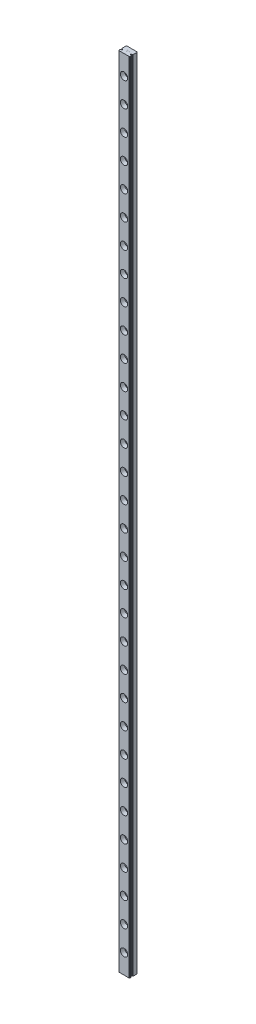
from build123d import *

# Parameters (mm, degrees)
SALIENTE_EXTRUIR1_DEPTH = 652
CORTAR_EXTRUIR1_DEPTH   = 653
CORTAR_EXTRUIR2_DEPTH   = 653
CORTAR_EXTRUIR3_DEPTH   = 653
CORTAR_EXTRUIR4_DEPTH   = 653
CORTAR_EXTRUIR5_DEPTH   = 653
CORTAR_EXTRUIR6_DEPTH   = 653
CORTAR_EXTRUIR7_DEPTH   = 0.002166667
CORTAR_EXTRUIR8_DEPTH   = 0.002166667
CORTAR_EXTRUIR9_DEPTH   = 0.002166667
CORTAR_EXTRUIR10_DEPTH  = 0.002166667
NGULO_DE_SALIDA1_ANGLE  = 45.1469538
CHAFL_N1_SIZE           = 0.4
REDONDEO1_R             = 0.130000023
MATRIZL2_COUNT          = 32
MATRIZL2_PITCH          = 20


with BuildPart() as part:
    # Croquis1 → Saliente-Extruir1 (new body)
    with BuildSketch(Plane.XZ):
        Polygon((4.5, 0), (4.5, 6.01167813), (4.1, 6.50000002), (-4.1, 6.50000002), (-4.5, 6.01167813), (-4.5, 0), align=None)
    extrude(amount=-SALIENTE_EXTRUIR1_DEPTH)

    # Croquis2 → Cortar-Extruir1 (cut, through all)
    with BuildSketch(Plane(origin=(0, 652, 0), x_dir=(-1, 0, 0), z_dir=(0, 1, 0))):
        with BuildLine():
            Line((-4.5, 4.88017535), (-4.5, 4.03150278))
            Line((-4.5, 4.03150278), (-3.819258765, 4.03150278))
            ThreePointArc((-3.819258765, 4.03150278), (-3.21946318, 4.455839065), (-3.819258765, 4.88017535))
            Line((-3.819258765, 4.88017535), (-4.5, 4.88017535))
        make_face()
    extrude(amount=-CORTAR_EXTRUIR1_DEPTH, mode=Mode.SUBTRACT)

    # Croquis3 → Cortar-Extruir2 (cut, through all)
    with BuildSketch(Plane(origin=(0, 652, 0), x_dir=(-1, 0, 0), z_dir=(0, 1, 0))):
        with BuildLine():
            Line((-4.026513856, 4.03150278), (-4.5, 4.03150278))
            Line((-4.5, 4.03150278), (-4.5, 3.583620931))
            ThreePointArc((-4.5, 3.583620931), (-4.223645982, 3.76568645), (-4.026513856, 4.03150278))
        make_face()
    extrude(amount=-CORTAR_EXTRUIR2_DEPTH, mode=Mode.SUBTRACT)

    # Croquis4 → Cortar-Extruir3 (cut, through all)
    with BuildSketch(Plane(origin=(0, 652, 0), x_dir=(-1, 0, 0), z_dir=(0, 1, 0))):
        with BuildLine():
            Line((-4.5, 5.328056964), (-4.5, 4.88017535))
            Line((-4.5, 4.88017535), (-4.026513974, 4.88017535))
            ThreePointArc((-4.026513974, 4.88017535), (-4.223646078, 5.145991535), (-4.5, 5.328056964))
        make_face()
    extrude(amount=-CORTAR_EXTRUIR3_DEPTH, mode=Mode.SUBTRACT)

    # Croquis5 → Cortar-Extruir4 (cut, through all)
    with BuildSketch(Plane(origin=(0, 652, 0), x_dir=(-1, 0, 0), z_dir=(0, 1, 0))):
        with BuildLine():
            Line((4.5, 4.03150278), (4.5, 4.88017535))
            Line((4.5, 4.88017535), (3.819258765, 4.88017535))
            ThreePointArc((3.819258765, 4.88017535), (3.21946318, 4.455839065), (3.819258765, 4.03150278))
            Line((3.819258765, 4.03150278), (4.5, 4.03150278))
        make_face()
    extrude(amount=-CORTAR_EXTRUIR4_DEPTH, mode=Mode.SUBTRACT)

    # Croquis6 → Cortar-Extruir5 (cut, through all)
    with BuildSketch(Plane(origin=(0, 652, 0), x_dir=(-1, 0, 0), z_dir=(0, 1, 0))):
        with BuildLine():
            Line((4.026513826, 4.88017535), (4.5, 4.88017535))
            Line((4.5, 4.88017535), (4.5, 5.328057255))
            ThreePointArc((4.5, 5.328057255), (4.223645966, 5.145991706), (4.026513826, 4.88017535))
        make_face()
    extrude(amount=-CORTAR_EXTRUIR5_DEPTH, mode=Mode.SUBTRACT)

    # Croquis7 → Cortar-Extruir6 (cut, through all)
    with BuildSketch(Plane(origin=(0, 652, 0), x_dir=(-1, 0, 0), z_dir=(0, 1, 0))):
        with BuildLine():
            Line((4.5, 3.583620926), (4.5, 4.03150278))
            Line((4.5, 4.03150278), (4.026513851, 4.03150278))
            ThreePointArc((4.026513851, 4.03150278), (4.223645987, 3.765686455), (4.5, 3.583620926))
        make_face()
    extrude(amount=-CORTAR_EXTRUIR6_DEPTH, mode=Mode.SUBTRACT)

    # Croquis8 → Cortar-Extruir7 (cut)
    with BuildSketch(Plane(origin=(0, 652, 0), x_dir=(-1, 0, 0), z_dir=(0, 1, 0))):
        Polygon((0.891369267, 3.403698133), (0.714701433, 3.168235633), (0.2187042, 2.61105), (1.0945792, 2.61105), (1.0945792, 2.695983333), (0.398689633, 2.695983333), (0.794326433, 3.149466667), (0.9743123, 3.3891), (1.067110588, 3.573407857), (0.95413722, 3.802321701), (0.7876908, 3.88505), (0.54301, 3.88505), (0.375434678, 3.803592619), (0.295011167, 3.6384023), (0.295011167, 3.562), (0.3812718, 3.562), (0.3812718, 3.631766667), (0.437672733, 3.743620833), (0.549645633, 3.800116667), (0.7802262, 3.800116667), (0.893028067, 3.743810633), (0.976240026, 3.576039029), align=None)
    extrude(amount=-CORTAR_EXTRUIR7_DEPTH, mode=Mode.SUBTRACT)

    # Croquis9 → Cortar-Extruir8 (cut)
    with BuildSketch(Plane.XZ):
        Polygon((-0.214632167, 3.88505), (-0.953983333, 3.88505), (-0.953983333, 2.61105), (-0.214632167, 2.61105), (-0.214632167, 2.695983333), (-0.86905, 2.695983333), (-0.86905, 3.205583333), (-0.5123963, 3.205583333), (-0.5123963, 3.290516667), (-0.86905, 3.290516667), (-0.86905, 3.800116667), (-0.214632167, 3.800116667), align=None)
    extrude(amount=-CORTAR_EXTRUIR8_DEPTH, mode=Mode.SUBTRACT)

    # Croquis10 → Cortar-Extruir9 (cut)
    with BuildSketch(Plane(origin=(0, 652, 0), x_dir=(-1, 0, 0), z_dir=(0, 1, 0))):
        Polygon((-0.214632167, 3.88505), (-0.953983333, 3.88505), (-0.953983333, 2.61105), (-0.214632167, 2.61105), (-0.214632167, 2.695983333), (-0.86905, 2.695983333), (-0.86905, 3.205583333), (-0.5123963, 3.205583333), (-0.5123963, 3.290516667), (-0.86905, 3.290516667), (-0.86905, 3.800116667), (-0.214632167, 3.800116667), align=None)
    extrude(amount=-CORTAR_EXTRUIR9_DEPTH, mode=Mode.SUBTRACT)

    # Croquis11 → Cortar-Extruir10 (cut)
    with BuildSketch(Plane.XZ):
        Polygon((0.510057167, 3.620830633), (0.6071, 3.718655633), (0.6071, 2.609403333), (0.692033333, 2.609403333), (0.692033333, 3.883403333), (0.6741176, 3.883403333), (0.6741176, 3.795069794), (0.3690544, 3.640736667), (0.3690544, 3.551253333), align=None)
    extrude(amount=-CORTAR_EXTRUIR10_DEPTH, mode=Mode.SUBTRACT)

    # Ángulo de salida1
    ngulo_de_salida1_faces = [part.faces().sort_by_distance(p)[0] for p in [
        (0.6741176, 0.001083333, 3.839236564),
    ]]
    draft(ngulo_de_salida1_faces, Plane(origin=(0.692033333, 0.002166667, 3.883403333), x_dir=(-1, 0, 0), z_dir=(0, 0, -1)), NGULO_DE_SALIDA1_ANGLE)

    # Chaflán1
    chafl_n1_edges = [part.edges().sort_by_distance(p)[0] for p in [
        (-4.5, 326, 0),
        (4.5, 326, 0),
    ]]
    chamfer(chafl_n1_edges, length=CHAFL_N1_SIZE)

    # Redondeo1
    redondeo1_edges = [part.edges().sort_by_distance(p)[0] for p in [
        (4.026513856, 326, 4.03150278),
        (4.5, 326, 3.583620931),
        (4.5, 326, 5.328056964),
        (4.026513974, 326, 4.88017535),
        (-4.026513826, 326, 4.88017535),
        (-4.5, 326, 5.328057255),
        (-4.5, 326, 3.583620926),
        (-4.026513851, 326, 4.03150278),
    ]]
    fillet(redondeo1_edges, radius=REDONDEO1_R)

    # Croquis34 → Taladro roscado M3.5x0.61 (revolve, cut)
    with BuildSketch(Plane(origin=(0, 16, 0), x_dir=(0, 1, 0), z_dir=(1, 0, 0))):
        Polygon((0, 0), (0, 8), (3, 8), (3, 3), (1.75, 3), (1.75, 0), align=None)
    taladro_roscado_m3_5x0_61 = revolve(axis=Axis((0, 16, -6.35), (0, 0, 1)), mode=Mode.SUBTRACT)

    # MatrizL2: Taladro roscado M3.5x0.61 ×32
    with Locations(*[(0, i * MATRIZL2_PITCH, 0) for i in range(1, MATRIZL2_COUNT)]):
        add(taladro_roscado_m3_5x0_61, mode=Mode.SUBTRACT)


solid = part.part
